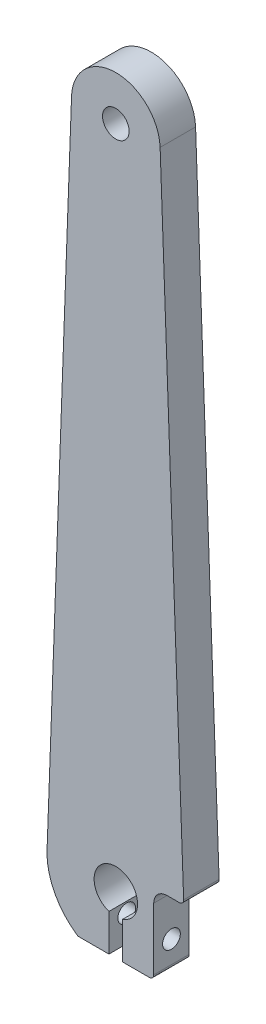
from build123d import *

# Parameters (mm, degrees)
SKETCH1_W           = 32
SKETCH1_H           = 173
BOSS_EXTRUDE2_DEPTH = 8
SKETCH3_R           = 4.9
SKETCH3_R_2         = 3
SKETCH3_W           = 3.1
SKETCH3_H           = 8.35
CUT_EXTRUDE1_DEPTH  = 9
CUT_EXTRUDE4_DEPTH  = 9
FILLET1_R           = 1
FILLET3_R           = 1
FILLET5_R           = 3
FILLET6_R           = 0.5
SKETCH7_R           = 2
CUT_EXTRUDE5_DEPTH  = 25.1


with BuildPart() as part:
    # Sketch1 → Boss-Extrude2 (new body)
    with BuildSketch(Plane.XY):
        Rectangle(SKETCH1_W, SKETCH1_H)
    extrude(amount=BOSS_EXTRUDE2_DEPTH)

    # Sketch3 → Cut-Extrude1 (cut, through all)
    with BuildSketch(Plane.XY.offset(8)):
        with Locations((0, -73.5)):
            Circle(SKETCH3_R)
        with Locations((0, 76.5)):
            Circle(SKETCH3_R_2)
        with Locations((0, -82.325)):
            Rectangle(SKETCH3_W, SKETCH3_H)
    extrude(amount=-CUT_EXTRUDE1_DEPTH, mode=Mode.SUBTRACT)

    # Sketch5 → Cut-Extrude4 (cut, through all)
    with BuildSketch(Plane.XY.offset(8)):
        with BuildLine():
            Line((-16, 86.5), (-16, -86.5))
            Line((-16, -86.5), (-15.540973095, -74.029769072))
            ThreePointArc((-15.540973095, -74.029769072), (-15.53947586, -72.927994754), (-15.459966578, -71.829092044))
            Line((-15.459966578, -71.829092044), (-10, 76.5))
            ThreePointArc((-10, 76.5), (-7.07106782, 83.571067803), (-2.4e-08, 86.5))
            Line((-2.4e-08, 86.5), (-16, 86.5))
        make_face()
        with BuildLine():
            Line((16, 86.5), (-2.4e-08, 86.5))
            ThreePointArc((-2.4e-08, 86.5), (6.939944042, 83.699803935), (9.993247284, 76.867435316))
            Line((9.993247284, 76.867435316), (15.338169515, -68.5))
            Line((15.338169515, -68.5), (8.55, -68.5))
            Line((8.55, -68.5), (8.55, -86.5))
            Line((8.55, -86.5), (16, -86.5))
            Line((16, -86.5), (16, 86.5))
        make_face()
        with BuildLine():
            Line((-15.540973095, -74.029769072), (-16, -86.5))
            Line((-16, -86.5), (-8.532438104, -86.5))
            ThreePointArc((-8.532438104, -86.5), (-13.555771706, -81.118631994), (-15.540973095, -74.029769072))
        make_face()
    extrude(amount=-CUT_EXTRUDE4_DEPTH, mode=Mode.SUBTRACT)

    # Fillet1
    fillet1_edges = [part.edges().sort_by_distance(p)[0] for p in [
        (8.55, -86.5, 4),
    ]]
    fillet(fillet1_edges, radius=FILLET1_R)

    # Fillet3
    fillet3_edges = [part.edges().sort_by_distance(p)[0] for p in [
        (15.338169515, -68.5, 4),
    ]]
    fillet(fillet3_edges, radius=FILLET3_R)

    # Fillet5
    fillet5_edges = [part.edges().sort_by_distance(p)[0] for p in [
        (8.55, -68.5, 4),
    ]]
    fillet(fillet5_edges, radius=FILLET5_R)

    # Fillet6
    fillet6_edges = [part.edges().sort_by_distance(p)[0] for p in [
        (-8.532438104, -86.5, 4),
    ]]
    fillet(fillet6_edges, radius=FILLET6_R)

    # Sketch7 → Cut-Extrude5 (cut, through all)
    with BuildSketch(Plane(origin=(8.55, 0, 0), x_dir=(0, 0, -1), z_dir=(1, 0, 0))):
        with Locations((-4, -80.5)):
            Circle(SKETCH7_R)
    extrude(amount=-CUT_EXTRUDE5_DEPTH, mode=Mode.SUBTRACT)


solid = part.part
